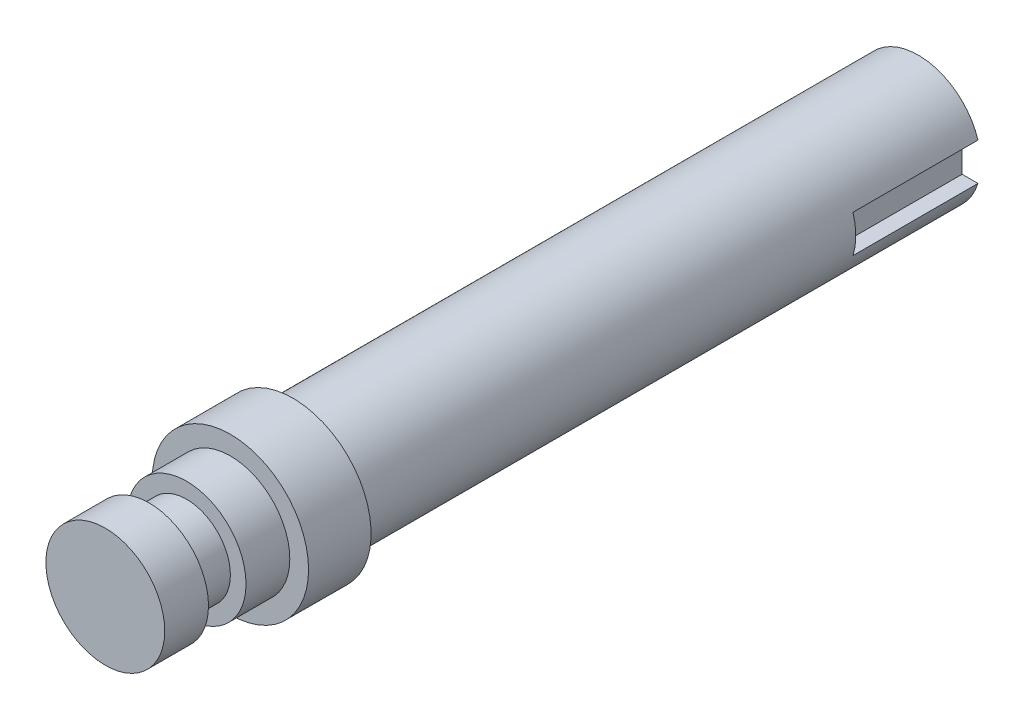
from build123d import *

# Parameters (mm, degrees)
IZIM1_R                     = 12.5
Y_KSEKLIK_EKSTR_ZYON1_DEPTH = 65
IZIM2_R                     = 12.5
IZIM2_R_2                   = 10
KES_EKSTR_ZYON1_DEPTH       = 100
IZIM3_W                     = 20
IZIM3_H                     = 6
KES_EKSTR_ZYON2_DEPTH       = 3
IZIM4_R                     = 12.5
IZIM4_R_2                   = 9.5
KES_EKSTR_ZYON3_DEPTH       = 7
IZIM5_R                     = 12.5
IZIM5_R_2                   = 7
KES_EKSTR_ZYON4_DEPTH       = 6
IZIM6_R                     = 12.5
IZIM6_R_2                   = 9.5
KES_EKSTR_ZYON5_DEPTH       = 7


with BuildPart() as part:
    # Çizim1 → Yükseklik-Ekstrüzyon1 (new body, symmetric)
    with BuildSketch(Plane.XY):
        Circle(IZIM1_R)
    extrude(amount=Y_KSEKLIK_EKSTR_ZYON1_DEPTH, both=True)

    # Çizim2 → Kes-Ekstrüzyon1 (cut)
    with BuildSketch(Plane(origin=(0, 0, -65), x_dir=(-1, 0, 0), z_dir=(0, 0, -1))):
        Circle(IZIM2_R)
        Circle(IZIM2_R_2, mode=Mode.SUBTRACT)
    extrude(amount=-KES_EKSTR_ZYON1_DEPTH, mode=Mode.SUBTRACT)

    # Çizim3 → Kes-Ekstrüzyon2 (cut)
    with BuildSketch(Plane(origin=(10, 0, 0), x_dir=(0, 0, -1), z_dir=(1, 0, 0))):
        with Locations((55, 0)):
            Rectangle(IZIM3_W, IZIM3_H)
    extrude(amount=-KES_EKSTR_ZYON2_DEPTH, mode=Mode.SUBTRACT)

    # Çizim4 → Kes-Ekstrüzyon3 (cut)
    with BuildSketch(Plane.XY.offset(65)):
        Circle(IZIM4_R)
        Circle(IZIM4_R_2, mode=Mode.SUBTRACT)
    extrude(amount=-KES_EKSTR_ZYON3_DEPTH, mode=Mode.SUBTRACT)

    # Çizim5 → Kes-Ekstrüzyon4 (cut)
    with BuildSketch(Plane.XY.offset(58)):
        Circle(IZIM5_R)
        Circle(IZIM5_R_2, mode=Mode.SUBTRACT)
    extrude(amount=-KES_EKSTR_ZYON4_DEPTH, mode=Mode.SUBTRACT)

    # Çizim6 → Kes-Ekstrüzyon5 (cut)
    with BuildSketch(Plane.XY.offset(52)):
        Circle(IZIM6_R)
        Circle(IZIM6_R_2, mode=Mode.SUBTRACT)
    extrude(amount=-KES_EKSTR_ZYON5_DEPTH, mode=Mode.SUBTRACT)


solid = part.part
